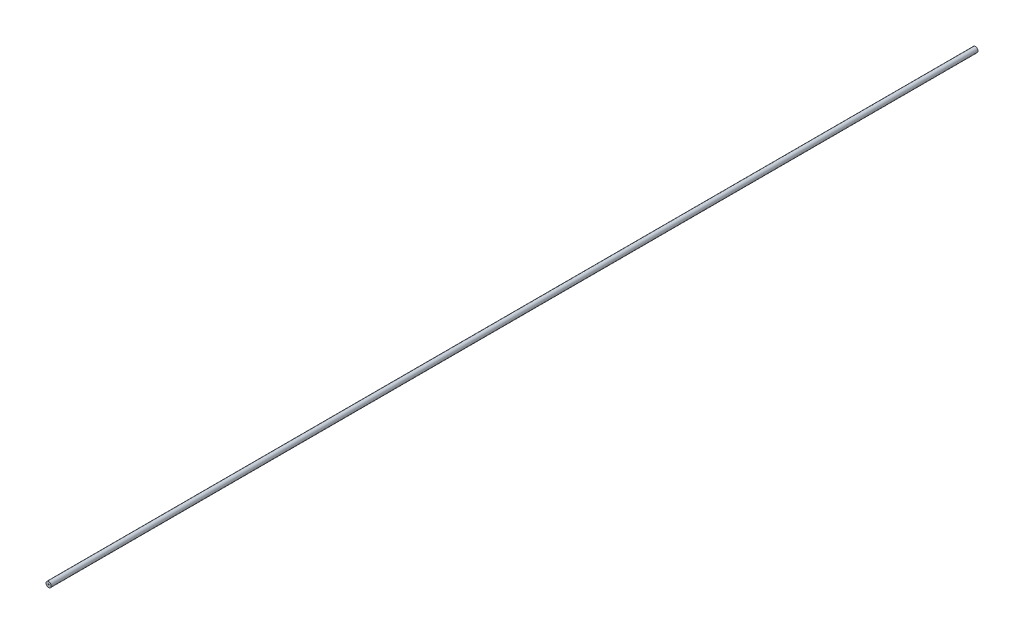
from build123d import *

# Parameters (mm, degrees)
SKETCH2_R           = 2.75
SKETCH2_R_2         = 0.5
BOSS_EXTRUDE1_DEPTH = 488.69607


with BuildPart() as part:
    # Sketch2 → Boss-Extrude1 (new, symmetric)
    with BuildSketch(Plane.XY):
        Circle(SKETCH2_R)
        Circle(SKETCH2_R_2, mode=Mode.SUBTRACT)
    extrude(amount=BOSS_EXTRUDE1_DEPTH, both=True)


solid = part.part
